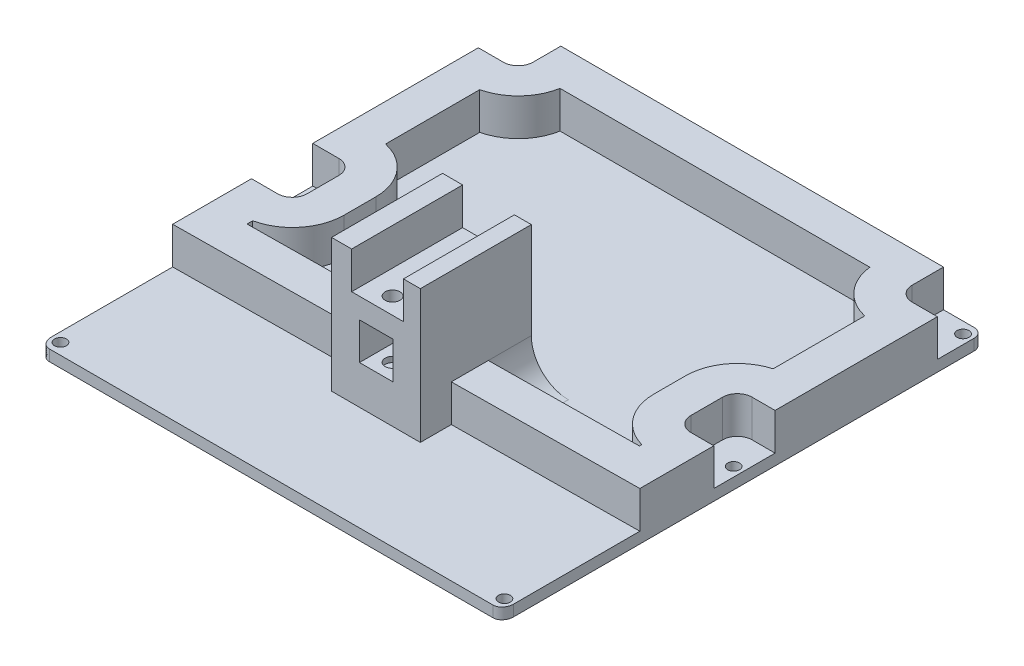
from build123d import *

# Parameters (mm, degrees)
SKETCH1_R           = 1.6
BOSS_EXTRUDE1_DEPTH = 3
BOSS_EXTRUDE2_DEPTH = 10
SKETCH4_W           = 24
SKETCH4_H           = 30
BOSS_EXTRUDE3_DEPTH = 36
SKETCH5_W           = 14
SKETCH5_H           = 46.886122037
CUT_EXTRUDE1_DEPTH  = 10
FILLET1_R           = 10
SKETCH6_R           = 2
CUT_EXTRUDE2_DEPTH  = 17
SKETCH7_W           = 9
SKETCH7_H           = 10
CUT_EXTRUDE3_DEPTH  = 43


with BuildPart() as part:
    # Sketch1 → Boss-Extrude1 (new body)
    with BuildSketch(Plane(origin=(0, 0, 0), x_dir=(-1, 0, 0), z_dir=(0, 1, 0))):
        with BuildLine():
            Line((60, 65), (-60, 65))
            add(Edge.make_bspline(
                [(-60, 65), (-60.182819281, 65), (-60.361318877, 64.975540463), (-60.710305196, 64.881249752), (-60.880306062, 64.810741327), (-61.195311527, 64.634632862), (-61.344175944, 64.527049534), (-61.613989028, 64.285865538), (-61.735638417, 64.152370239), (-62.06437147, 63.716635859), (-62.227421468, 63.389720941), (-62.445894576, 62.69875639), (-62.5, 62.340611149), (-62.5, 61.976586008)],
                knots=[0, 0, 0, 0, 0.125, 0.125, 0.25, 0.25, 0.375, 0.375, 0.5, 0.5, 0.75, 0.75, 1, 1, 1, 1], degree=3))
            Line((-62.5, 61.976586008), (-62.5, -62.5))
            ThreePointArc((-62.5, -62.5), (-61.767766953, -64.267766953), (-60, -65))
            Line((-60, -65), (60, -65))
            ThreePointArc((60, -65), (61.767766953, -64.267766953), (62.5, -62.5))
            Line((62.5, -62.5), (62.5, 61.976586008))
            add(Edge.make_bspline(
                [(62.5, 61.976586008), (62.5, 62.34175037), (62.44618995, 62.696231112), (62.283935978, 63.211763232), (62.214956517, 63.382489596), (62.051620496, 63.705029242), (61.957290328, 63.857858356), (61.741427498, 64.145383151), (61.618346212, 64.281498062), (61.347304427, 64.524712758), (61.20089923, 64.631048566), (60.883593427, 64.80935119), (60.713329195, 64.880102966), (60.36541887, 64.974755775), (60.183838083, 65), (60, 65)],
                knots=[0, 0, 0, 0, 0.25, 0.25, 0.375, 0.375, 0.5, 0.5, 0.625, 0.625, 0.75, 0.75, 0.875, 0.875, 1, 1, 1, 1], degree=3))
        make_face()
        with Locations((60, 61.976586008)):
            Circle(SKETCH1_R, mode=Mode.SUBTRACT)
        with Locations((-60, 61.976586008)):
            Circle(SKETCH1_R, mode=Mode.SUBTRACT)
        with Locations((-60, 0.023413992)):
            Circle(SKETCH1_R, mode=Mode.SUBTRACT)
        with Locations((60, 0.023413992)):
            Circle(SKETCH1_R, mode=Mode.SUBTRACT)
        with Locations((-60, -61.976586008)):
            Circle(SKETCH1_R, mode=Mode.SUBTRACT)
        with Locations((60, -61.976586008)):
            Circle(SKETCH1_R, mode=Mode.SUBTRACT)
    extrude(amount=BOSS_EXTRUDE1_DEPTH)

    # Sketch2 → Boss-Extrude2 (add)
    with BuildSketch(Plane(origin=(0, 3, 0), x_dir=(1, 0, 0), z_dir=(0, 1, 0))):
        with BuildLine():
            Line((-62.5, -29.161742213), (62.5, -27.875786008))
            Line((62.5, -27.875786008), (62.5, -7.87481403))
            Line((62.5, -7.87481403), (56.297106888, -7.87481403))
            ThreePointArc((56.297106888, -7.87481403), (53.468679763, -6.703241155), (52.297106888, -3.87481403))
            Line((52.297106888, -3.87481403), (52.297106888, 4.677057962))
            ThreePointArc((52.297106888, 4.677057962), (53.468679763, 7.505485087), (56.297106888, 8.677057962))
            Line((56.297106888, 8.677057962), (62.5, 8.677057962))
            Line((62.5, 8.677057962), (62.5, 52.543812316))
            Line((62.5, 52.543812316), (55.701817461, 52.543812316))
            ThreePointArc((55.701817461, 52.543812316), (52.873390337, 53.715385191), (51.701817461, 56.543812316))
            Line((51.701817461, 56.543812316), (51.701817461, 65))
            Line((51.701817461, 65), (-51.729569497, 65))
            Line((-51.729569497, 65), (-51.729569497, 57.468140355))
            ThreePointArc((-51.729569497, 57.468140355), (-52.901142372, 54.63971323), (-55.729569497, 53.468140355))
            Line((-55.729569497, 53.468140355), (-62.5, 53.468140355))
            Line((-62.5, 53.468140355), (-62.5, 8.709965682))
            Line((-62.5, 8.709965682), (-55.456914608, 8.709965682))
            ThreePointArc((-55.456914608, 8.709965682), (-52.628487483, 7.538392807), (-51.456914608, 4.709965682))
            Line((-51.456914608, 4.709965682), (-51.456914608, -3.84190631))
            ThreePointArc((-51.456914608, -3.84190631), (-52.628487483, -6.670333435), (-55.456914608, -7.84190631))
            Line((-55.456914608, -7.84190631), (-62.5, -7.84190631))
            Line((-62.5, -7.84190631), (-62.5, -29.161742213))
        make_face()
        with BuildLine():
            Line((-52.5, -19.058336552), (52.5, -17.97813334))
            Line((52.5, -17.97813334), (52.5, -17.350049809))
            ThreePointArc((52.5, -17.350049809), (45.135577055, -12.325864367), (42.297106888, -3.87481403))
            Line((42.297106888, -3.87481403), (42.297106888, 4.677057962))
            ThreePointArc((42.297106888, 4.677057962), (45.135577055, 13.128108299), (52.5, 18.152293741))
            Line((52.5, 18.152293741), (52.5, 42.91485913))
            ThreePointArc((52.5, 42.91485913), (45.225378973, 47.257034801), (41.787197684, 55))
            Line((41.787197684, 55), (-41.948848065, 55))
            ThreePointArc((-41.948848065, 55), (-45.558930544, 47.847428152), (-52.5, 43.845736717))
            Line((-52.5, 43.845736717), (-52.5, 18.394141068))
            ThreePointArc((-52.5, 18.394141068), (-44.562034973, 13.502098401), (-41.456914608, 4.709965682))
            Line((-41.456914608, 4.709965682), (-41.456914608, -3.84190631))
            ThreePointArc((-41.456914608, -3.84190631), (-44.562034973, -12.634039029), (-52.5, -17.526081697))
            Line((-52.5, -17.526081697), (-52.5, -19.058336552))
        make_face(mode=Mode.SUBTRACT)
    extrude(amount=BOSS_EXTRUDE2_DEPTH)

    # Sketch4 → Boss-Extrude3 (add)
    with BuildSketch(Plane(origin=(0, 3, 0), x_dir=(1, 0, 0), z_dir=(0, 1, 0))):
        with Locations((0.057489953, -21.76285015)):
            Rectangle(SKETCH4_W, SKETCH4_H)
    extrude(amount=BOSS_EXTRUDE3_DEPTH)

    # Sketch5 → Cut-Extrude1 (cut)
    with BuildSketch(Plane(origin=(0, 39, 0), x_dir=(1, 0, 0), z_dir=(0, 1, 0))):
        with Locations((0.487990249, -20.167047514)):
            Rectangle(SKETCH5_W, SKETCH5_H)
    extrude(amount=-CUT_EXTRUDE1_DEPTH, mode=Mode.SUBTRACT)

    # Fillet1
    fillet1_edges = [part.edges().sort_by_distance(p)[0] for p in [
        (12.057489953, 3, 12.578520932),
        (-11.942510047, 3, 12.701972727),
    ]]
    fillet(fillet1_edges, radius=FILLET1_R)

    # Sketch6 → Cut-Extrude2 (cut)
    with BuildSketch(Plane(origin=(0, 29, 0), x_dir=(1, 0, 0), z_dir=(0, 1, 0))):
        with Locations((0.290601946, -16.047289156)):
            Circle(SKETCH6_R)
        with Locations((0.030645041, -32.251269585)):
            Circle(SKETCH6_R)
    extrude(amount=-CUT_EXTRUDE2_DEPTH, mode=Mode.SUBTRACT)

    # Sketch7 → Cut-Extrude3 (cut)
    with BuildSketch(Plane.XY.offset(36.76285015)):
        with Locations((0.102375744, 18.47840537)):
            Rectangle(SKETCH7_W, SKETCH7_H)
    extrude(amount=-CUT_EXTRUDE3_DEPTH, mode=Mode.SUBTRACT)


solid = part.part
